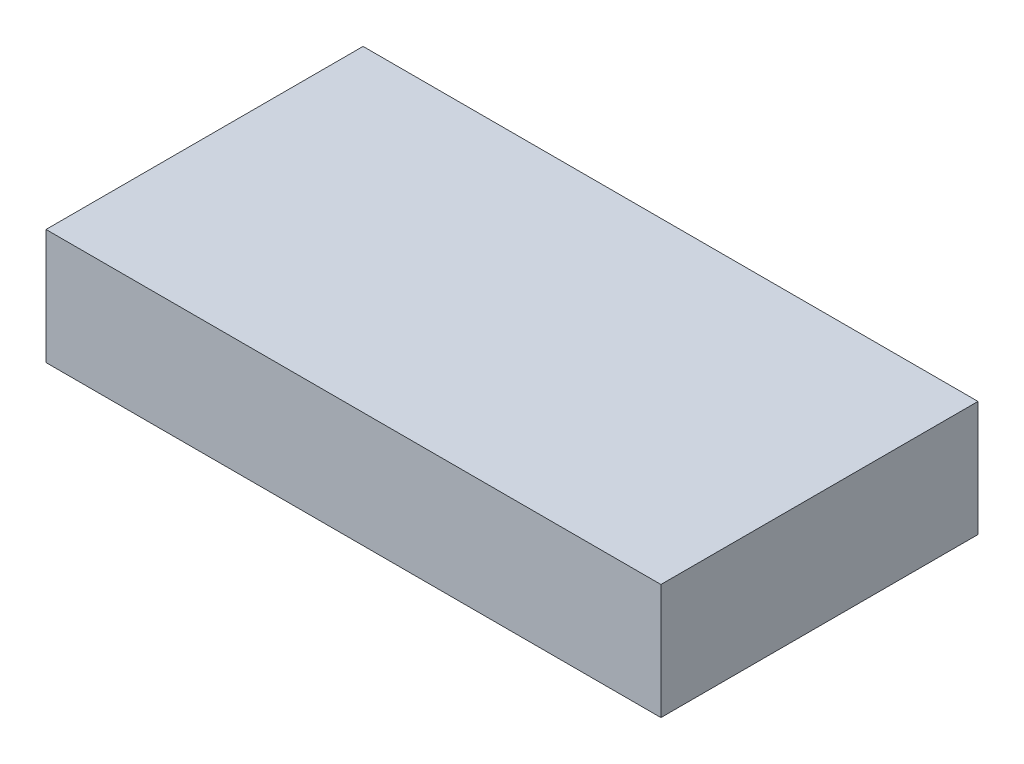
from build123d import *

# Parameters (mm, degrees)
SKETCH1_W           = 64
SKETCH1_H           = 33
BOSS_EXTRUDE1_DEPTH = 12


with BuildPart() as part:
    # Sketch1 → Boss-Extrude1 (new body)
    with BuildSketch(Plane(origin=(0, 0, 0), x_dir=(1, 0, 0), z_dir=(0, 1, 0))):
        with Locations((7.905882353, -19.637254902)):
            Rectangle(SKETCH1_W, SKETCH1_H)
    extrude(amount=BOSS_EXTRUDE1_DEPTH)


solid = part.part
